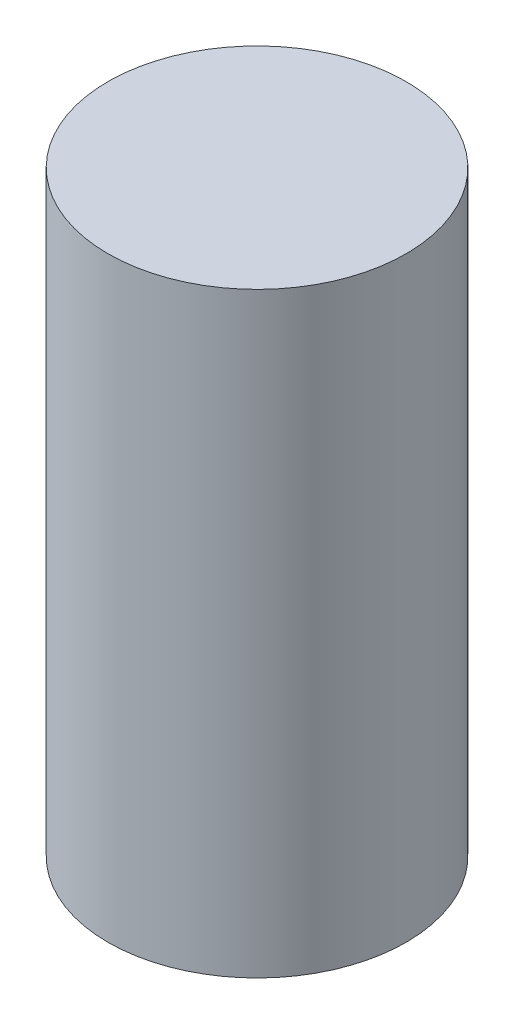
from build123d import *

# Parameters (mm, degrees)
SKETCH1_R           = 0.79375
BOSS_EXTRUDE1_DEPTH = 3.175


with BuildPart() as part:
    # Sketch1 → Boss-Extrude1 (new body)
    with BuildSketch(Plane(origin=(0, 0, 0), x_dir=(1, 0, 0), z_dir=(0, 1, 0))):
        Circle(SKETCH1_R)
    extrude(amount=BOSS_EXTRUDE1_DEPTH)


solid = part.part
